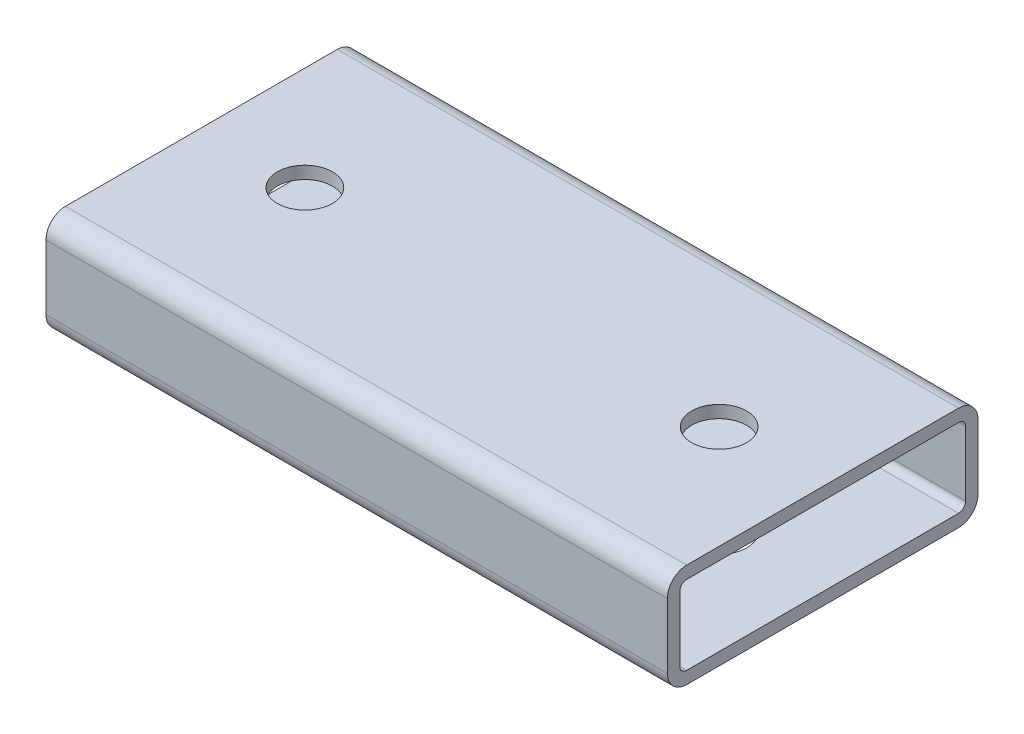
from build123d import *

# Parameters (mm, degrees)
RECTANGULAR_TUBE_3_X_2_X_0_25_1_DEPTH = 152.4
F_1_2_CLEARANCE_HOLE1_D               = 13.49248


with BuildPart() as part:
    # Sketch16 → Rectangular tube 3 X 2 X 0.25(1) (new body)
    with BuildSketch(Plane.ZY.offset(-76.2)):
        with BuildLine():
            Line((-33.3375, -12.7), (33.3375, -12.7))
            ThreePointArc((33.3375, -12.7), (36.705096045, -11.305096045), (38.1, -7.9375))
            Line((38.1, -7.9375), (38.1, 7.9375))
            ThreePointArc((38.1, 7.9375), (36.705096045, 11.305096045), (33.3375, 12.7))
            Line((33.3375, 12.7), (-33.3375, 12.7))
            ThreePointArc((-33.3375, 12.7), (-36.705096045, 11.305096045), (-38.1, 7.9375))
            Line((-38.1, 7.9375), (-38.1, -7.9375))
            ThreePointArc((-38.1, -7.9375), (-36.705096045, -11.305096045), (-33.3375, -12.7))
        make_face()
        with BuildLine():
            Line((-33.3375, -9.652), (33.3375, -9.652))
            ThreePointArc((33.3375, -9.652), (34.549834576, -9.149834576), (35.052, -7.9375))
            Line((35.052, -7.9375), (35.052, 7.9375))
            ThreePointArc((35.052, 7.9375), (34.549834576, 9.149834576), (33.3375, 9.652))
            Line((33.3375, 9.652), (-33.3375, 9.652))
            ThreePointArc((-33.3375, 9.652), (-34.549834576, 9.149834576), (-35.052, 7.9375))
            Line((-35.052, 7.9375), (-35.052, -7.9375))
            ThreePointArc((-35.052, -7.9375), (-34.549834576, -9.149834576), (-33.3375, -9.652))
        make_face(mode=Mode.SUBTRACT)
    extrude(amount=RECTANGULAR_TUBE_3_X_2_X_0_25_1_DEPTH)

    # 1/2 Clearance Hole1 (through all)
    with Locations(Plane(origin=(0, 12.7, 0), x_dir=(1, 0, 0), z_dir=(0, 1, 0))):
        with Locations((-50.8, 0), (50.8, 0)):
            Hole(F_1_2_CLEARANCE_HOLE1_D / 2)


solid = part.part
